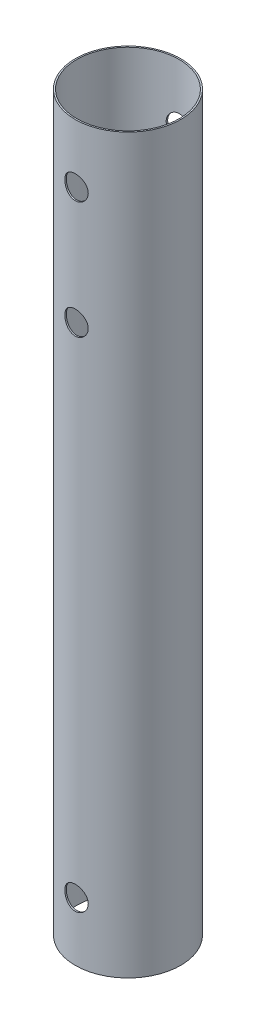
from build123d import *

# Parameters (mm, degrees)
SKETCH1_R               = 9
SKETCH1_R_2             = 8.75
BOSS_EXTRUDE1_DEPTH     = 125
SKETCH2_R               = 2
CUT_EXTRUDE1_DEPTH      = 10
CUT_EXTRUDE1_DEPTH_BACK = 10


with BuildPart() as part:
    # Sketch1 → Boss-Extrude1 (new body)
    with BuildSketch(Plane(origin=(0, 0, 0), x_dir=(1, 0, 0), z_dir=(0, 1, 0))):
        Circle(SKETCH1_R)
        Circle(SKETCH1_R_2, mode=Mode.SUBTRACT)
    extrude(amount=BOSS_EXTRUDE1_DEPTH)

    # Sketch2 → Cut-Extrude1 (cut, two sides)
    with BuildSketch(Plane.XY) as cut_extrude1_sk:
        with Locations((0, 95)):
            Circle(SKETCH2_R)
        with Locations((0, 115)):
            Circle(SKETCH2_R)
        with Locations((0, 10)):
            Circle(SKETCH2_R)
    extrude(amount=CUT_EXTRUDE1_DEPTH, mode=Mode.SUBTRACT)
    extrude(cut_extrude1_sk.sketch, amount=-CUT_EXTRUDE1_DEPTH_BACK, mode=Mode.SUBTRACT)


solid = part.part
